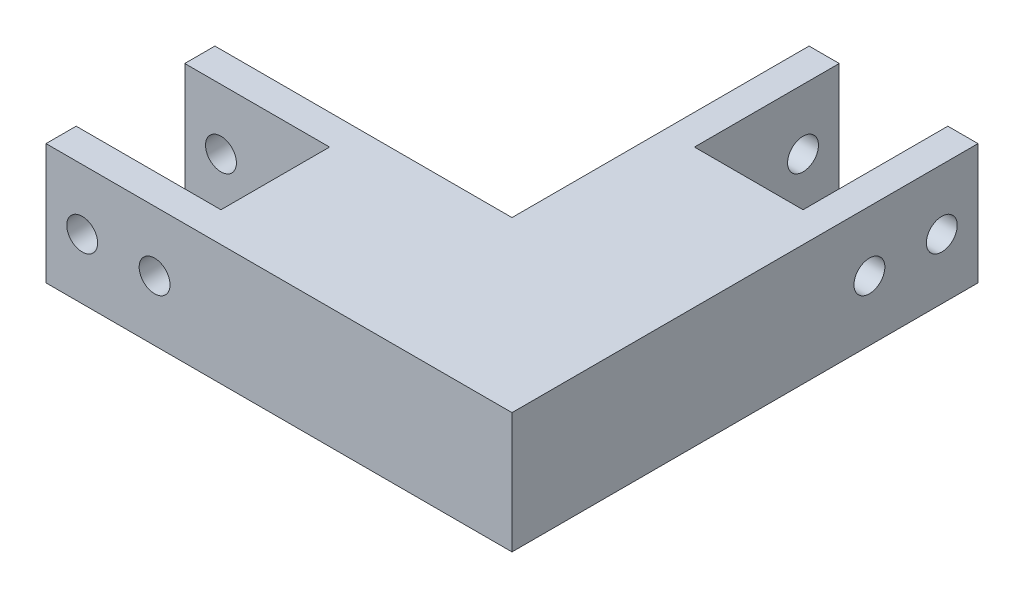
from build123d import *

# Parameters (mm, degrees)
EXTRUDE_1_DEPTH     = 25
SKETCH_2_R          = 3.2
CUT_EXTRUDE_1_DEPTH = 35
SKETCH_3_R          = 3.2
CUT_EXTRUDE_2_DEPTH = 35


with BuildPart() as part:
    # 스케치1 → 보스-돌출1 (new body)
    with BuildSketch(Plane(origin=(0, 0, 0), x_dir=(1, 0, 0), z_dir=(0, 1, 0))):
        Polygon((-17.5, 79.05), (-11.25, 79.05), (-11.25, 49.05), (11.25, 49.05), (11.25, 79.05), (17.5, 79.05), (17.5, -17.5), (-79.05, -17.5), (-79.05, -11.25), (-49.05, -11.25), (-49.05, 11.25), (-79.05, 11.25), (-79.05, 17.5), (-17.5, 17.5), align=None)
    extrude(amount=EXTRUDE_1_DEPTH)

    # 스케치2 → 컷-돌출1 (cut)
    with BuildSketch(Plane(origin=(17.5, 0, 0), x_dir=(0, 0, -1), z_dir=(1, 0, 0))):
        with Locations((71.55, 12.5)):
            Circle(SKETCH_2_R)
        with Locations((56.55, 12.5)):
            Circle(SKETCH_2_R)
    extrude(amount=-CUT_EXTRUDE_1_DEPTH, mode=Mode.SUBTRACT)

    # 스케치3 → 컷-돌출2 (cut)
    with BuildSketch(Plane.XY.offset(17.5)):
        with Locations((-71.55, 12.5)):
            Circle(SKETCH_3_R)
        with Locations((-56.55, 12.5)):
            Circle(SKETCH_3_R)
    extrude(amount=-CUT_EXTRUDE_2_DEPTH, mode=Mode.SUBTRACT)


solid = part.part
